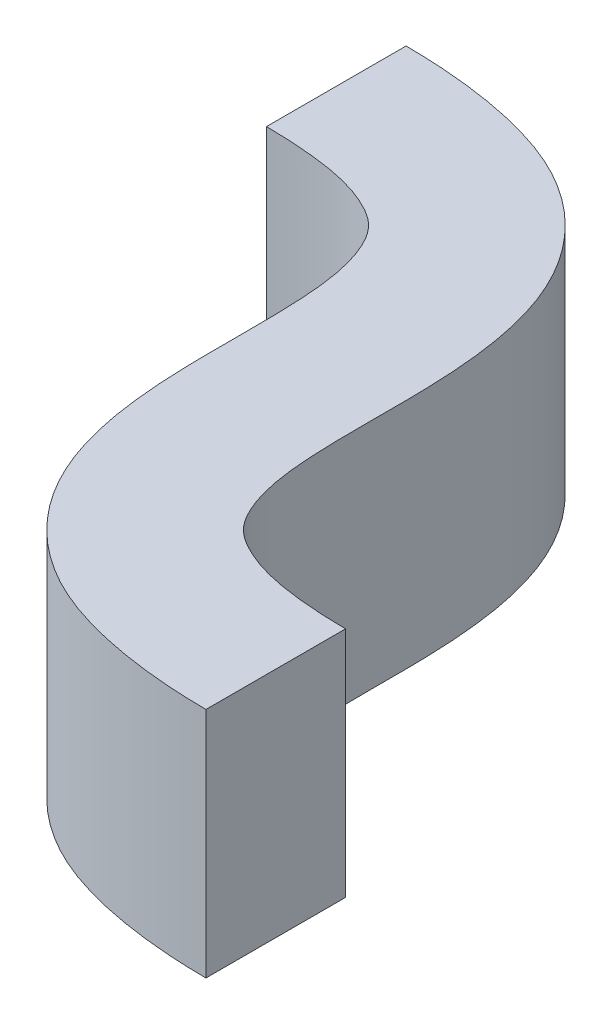
from build123d import *

# Parameters (mm, degrees)
BOSS_EXTRUDE1_DEPTH = 0.25


with BuildPart() as part:
    # Sketch1 → Boss-Extrude1 (new body, symmetric)
    with BuildSketch(Plane(origin=(0, 0, 0), x_dir=(1, 0, 0), z_dir=(0, 1, 0))):
        with BuildLine():
            Line((0, -0.15), (0, 0.15))
            add(Edge.make_bspline(
                [(0, 0.15), (0.120151792, 0.15), (0.385384773, 0.113888838), (0.601384368, -0.095842467), (0.661277487, -0.350560649), (0.659464905, -0.579419842), (0.660862894, -0.781759984), (0.69866774, -0.904638876), (0.751166188, -0.953669974), (0.864334193, -0.992097665), (0.97225533, -1), (1.02, -1)],
                knots=[0, 0, 0, 0, 0.125, 0.25, 0.375, 0.5, 0.625, 0.75, 0.875, 0.9375, 1, 1, 1, 1], degree=3))
            Line((1.02, -1), (1.02, -1.3))
            add(Edge.make_bspline(
                [(0, -0.15), (0.04774467, -0.15), (0.155665807, -0.157902335), (0.268833812, -0.196330026), (0.32133226, -0.245361124), (0.359137106, -0.368240016), (0.360535095, -0.570580158), (0.358722513, -0.799439351), (0.418615632, -1.054157533), (0.634615227, -1.263888838), (0.899848208, -1.3), (1.02, -1.3)],
                knots=[0, 0, 0, 0, 0.0625, 0.125, 0.25, 0.375, 0.5, 0.625, 0.75, 0.875, 1, 1, 1, 1], degree=3))
        make_face()
    extrude(amount=BOSS_EXTRUDE1_DEPTH, both=True)


solid = part.part
